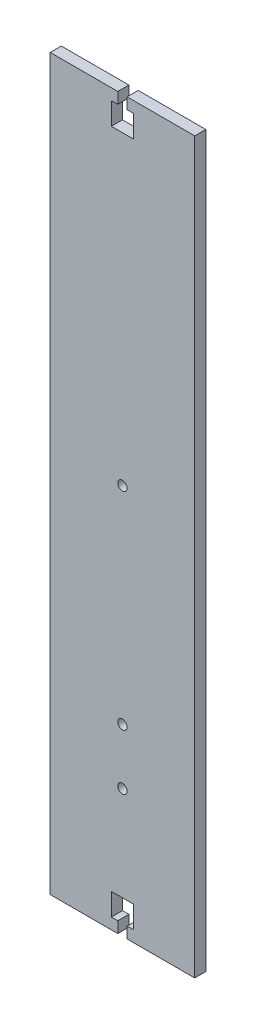
from build123d import *

# Parameters (mm, degrees)
SKETCH1_W           = 64.996
SKETCH1_H           = 328
BOSS_EXTRUDE1_DEPTH = 5
SKETCH2_R           = 2.1
CUT_EXTRUDE1_DEPTH  = 10
CUT_EXTRUDE2_DEPTH  = 10
SKETCH4_R           = 2.1
CUT_EXTRUDE3_DEPTH  = 5
SKETCH5_R           = 2.1
CUT_EXTRUDE4_DEPTH  = 5


with BuildPart() as part:
    # Sketch1 → Boss-Extrude1 (new body)
    with BuildSketch(Plane.XY):
        Rectangle(SKETCH1_W, SKETCH1_H)
    extrude(amount=BOSS_EXTRUDE1_DEPTH)

    # Sketch2 → Cut-Extrude1 (cut)
    with BuildSketch(Plane.XY.offset(5)):
        with Locations((0, -81.5)):
            Circle(SKETCH2_R)
    extrude(amount=-CUT_EXTRUDE1_DEPTH, mode=Mode.SUBTRACT)

    # Sketch3 → Cut-Extrude2 (cut)
    with BuildSketch(Plane.XY.offset(5)):
        Polygon((-2.1, 164), (2.1, 164), (2.1, 159), (5, 159), (5, 149), (-5, 149), (-5, 159), (-2.1, 159), align=None)
        Polygon((-2.1, -164), (-2.1, -159), (-5, -159), (-5, -149), (5, -149), (5, -159), (2.1, -159), (2.1, -164), align=None)
    extrude(amount=-CUT_EXTRUDE2_DEPTH, mode=Mode.SUBTRACT)

    # Sketch4 → Cut-Extrude3 (cut)
    with BuildSketch(Plane.XY.offset(5)):
        with Locations((0, -106.5)):
            Circle(SKETCH4_R)
    extrude(amount=-CUT_EXTRUDE3_DEPTH, mode=Mode.SUBTRACT)

    # Sketch5 → Cut-Extrude4 (cut)
    with BuildSketch(Plane.XY.offset(5)):
        with Locations((0, 11.5)):
            Circle(SKETCH5_R)
    extrude(amount=-CUT_EXTRUDE4_DEPTH, mode=Mode.SUBTRACT)


solid = part.part
